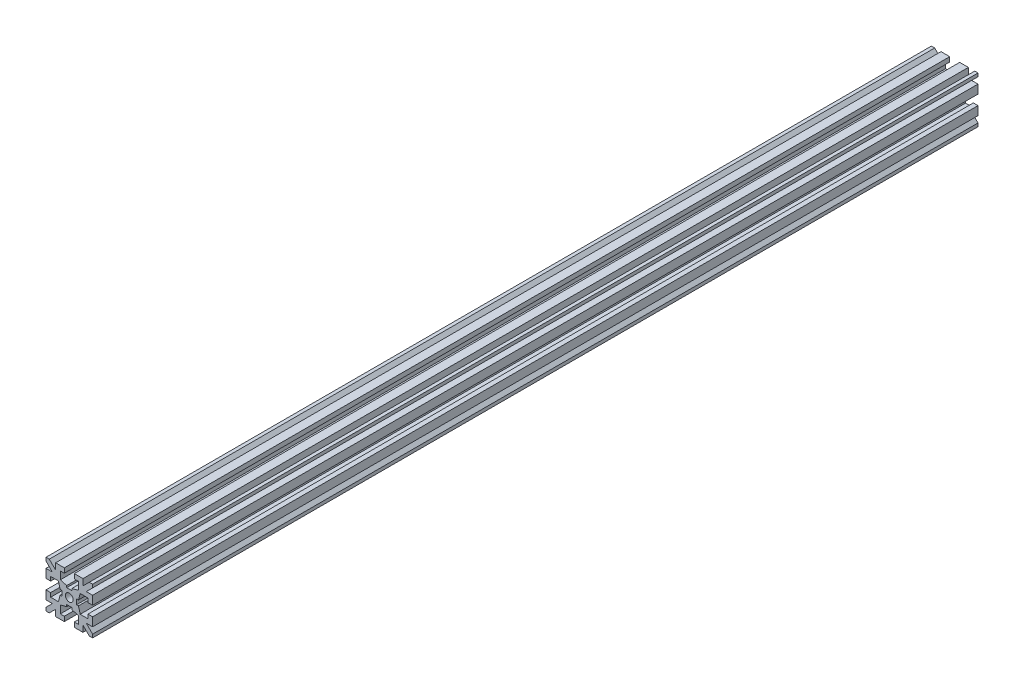
from build123d import *

# Parameters (mm, degrees)
RESSALTO_EXTRUS_O1_DEPTH   = 142.5
ESPELHAR2_COPY_1_DEPTH     = 142.5
ESBO_O2_R                  = 1.25
CORTE_EXTRUS_O1_DEPTH      = 1
CORTE_EXTRUS_O1_DEPTH_BACK = 286


with BuildPart() as part:
    # Esboço1 → Ressalto-extrusão1 (new body, symmetric)
    with BuildSketch(Plane.XY):
        Polygon((0, 2.35), (-0.825, 2.35), (-0.825, 2.95), (-2.9, 3.5), (-2.9, 6), (-1.6, 6), (-1.6, 7.5), (-4.4, 7.5), (-4.4, 5.460660172), (-6.439339828, 7.5), (-7.5, 7.5), (-7.5, 6.439339828), (-5.460660172, 4.4), (-7.5, 4.4), (-7.5, 1.6), (-6, 1.6), (-6, 2.9), (-3.5, 2.9), (-2.95, 0.825), (-2.35, 0.825), (-2.35, 0), (0, 0), align=None)
    ressalto_extrus_o1 = extrude(amount=RESSALTO_EXTRUS_O1_DEPTH, both=True)

    # Espelhar1: Ressalto-extrusão1 across plane
    add(ressalto_extrus_o1.mirror(Plane.ZX))

    # Espelhar2: Ressalto-extrusão1 across plane
    add(ressalto_extrus_o1.mirror(Plane(origin=(0, 0, 0), x_dir=(0, 0, 1), z_dir=(1, 0, 0))))

    # Espelhar2 copy 1 sketch → Espelhar2 copy 1 (add, symmetric)
    with BuildSketch(Plane(origin=(0, 0, 0), x_dir=(-1, 0, 0), z_dir=(0, 0, 1))):
        Polygon((0, 2.35), (-0.825, 2.35), (-0.825, 2.95), (-2.9, 3.5), (-2.9, 6), (-1.6, 6), (-1.6, 7.5), (-4.4, 7.5), (-4.4, 5.460660172), (-6.439339828, 7.5), (-7.5, 7.5), (-7.5, 6.439339828), (-5.460660172, 4.4), (-7.5, 4.4), (-7.5, 1.6), (-6, 1.6), (-6, 2.9), (-3.5, 2.9), (-2.95, 0.825), (-2.35, 0.825), (-2.35, 0), (0, 0), align=None)
    extrude(amount=ESPELHAR2_COPY_1_DEPTH, both=True)

    # Esboço2 → Corte-extrusão1 (cut, two sides)
    with BuildSketch(Plane.XY.offset(142.5)) as corte_extrus_o1_sk:
        Circle(ESBO_O2_R)
    extrude(amount=CORTE_EXTRUS_O1_DEPTH, mode=Mode.SUBTRACT)
    extrude(corte_extrus_o1_sk.sketch, amount=-CORTE_EXTRUS_O1_DEPTH_BACK, mode=Mode.SUBTRACT)


solid = part.part
